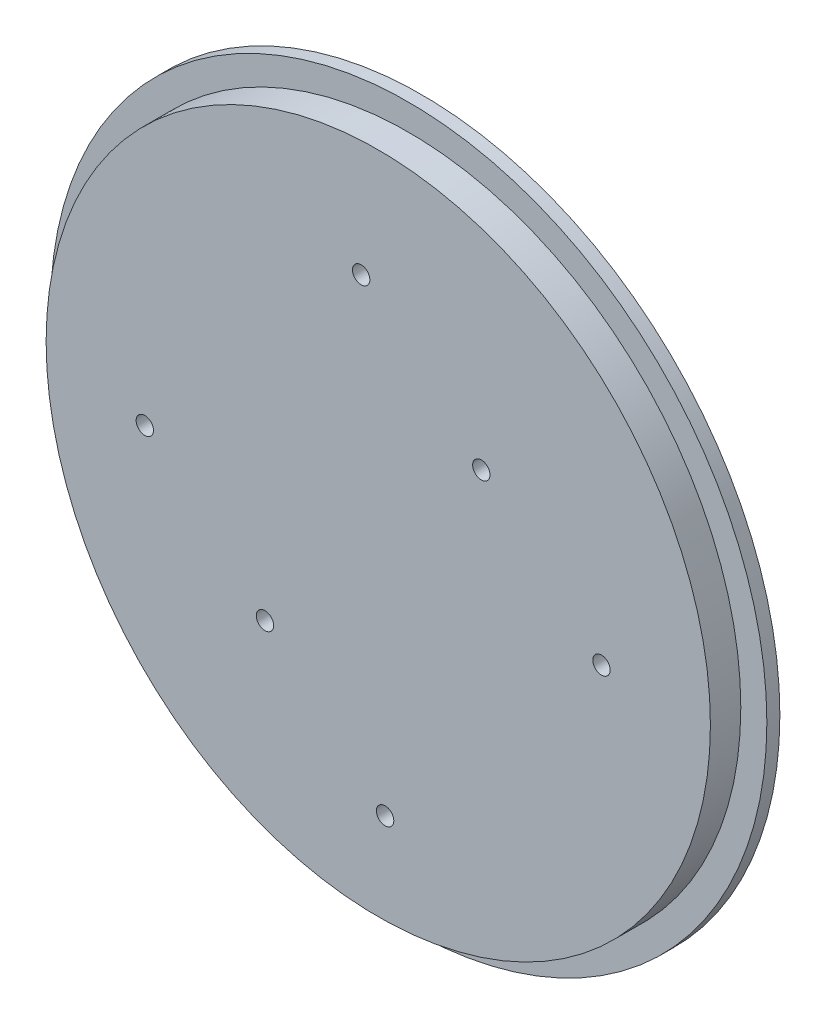
from build123d import *

# Parameters (mm, degrees)
ESBO_O1_R                = 82.5
ESBO_O1_R_2              = 14
RESSALTO_EXTRUS_O1_DEPTH = 3
ESBO_O2_R                = 5.925
RESSALTO_EXTRUS_O2_DEPTH = 8
ESBO_O3_R                = 14
RESSALTO_EXTRUS_O3_DEPTH = 3
ESBO_O4_R                = 10
RESSALTO_EXTRUS_O4_DEPTH = 11
ESBO_O5_R                = 3.05
CORTE_EXTRUS_O1_DEPTH    = 1
ESBO_O6_R                = 76.5
RESSALTO_EXTRUS_O5_DEPTH = 7
ESBO_O13_R               = 2
CORTE_EXTRUS_O2_DEPTH    = 11
ESBO_O14_R               = 7.5
CORTE_EXTRUS_O3_DEPTH    = 5


with BuildPart() as part:
    # Esboço1 → Ressalto-extrusão1 (new body)
    with BuildSketch(Plane.XY):
        Circle(ESBO_O1_R)
        Circle(ESBO_O1_R_2, mode=Mode.SUBTRACT)
    extrude(amount=RESSALTO_EXTRUS_O1_DEPTH)

    # Esboço2 → Ressalto-extrusão2 (add)
    with BuildSketch(Plane(origin=(0, 0, 0), x_dir=(-1, 0, 0), z_dir=(0, 0, -1))):
        with Locations((-55.155254038, 14.383947721)):
            Circle(ESBO_O2_R)
        with Locations((40.034491152, 40.573877288)):
            Circle(ESBO_O2_R)
        with Locations((15.120762886, -54.957825009)):
            Circle(ESBO_O2_R)
    extrude(amount=RESSALTO_EXTRUS_O2_DEPTH)

    # Esboço3 → Ressalto-extrusão3 (add)
    with BuildSketch(Plane.XY.offset(3)):
        Circle(ESBO_O3_R)
    extrude(amount=-RESSALTO_EXTRUS_O3_DEPTH)

    # Esboço4 → Ressalto-extrusão4 (add)
    with BuildSketch(Plane.XY.offset(3)):
        Circle(ESBO_O4_R)
    extrude(amount=-RESSALTO_EXTRUS_O4_DEPTH)

    # Esboço5 → Corte-extrusão1 (cut)
    with BuildSketch(Plane(origin=(0, 0, -8), x_dir=(-1, 0, 0), z_dir=(0, 0, -1))):
        Circle(ESBO_O5_R)
    extrude(amount=-CORTE_EXTRUS_O1_DEPTH, mode=Mode.SUBTRACT)

    # Esboço6 → Ressalto-extrusão5 (add)
    with BuildSketch(Plane.XY.offset(3)):
        Circle(ESBO_O6_R)
    extrude(amount=RESSALTO_EXTRUS_O5_DEPTH)

    # Esboço13 → Corte-extrusão2 (cut, through all)
    with BuildSketch(Plane(origin=(0, 0, 0), x_dir=(-1, 0, 0), z_dir=(0, 0, -1))):
        with Locations((-1.573494017, -55.549458165)):
            Circle(ESBO_O13_R)
        with Locations((26.098018566, -30.463408429)):
            Circle(ESBO_O13_R)
        with Locations((53.76953115, -5.377358693)):
            Circle(ESBO_O13_R)
        with Locations((-51.407244113, -0.579653936)):
            Circle(ESBO_O13_R)
        with Locations((-23.73573153, 24.5063958)):
            Circle(ESBO_O13_R)
        with Locations((3.935781053, 49.592445536)):
            Circle(ESBO_O13_R)
    extrude(amount=-CORTE_EXTRUS_O2_DEPTH, mode=Mode.SUBTRACT)

    # Esboço14 → Corte-extrusão3 (cut)
    with BuildSketch(Plane(origin=(0, 0, 0), x_dir=(-1, 0, 0), z_dir=(0, 0, -1))):
        with Locations((53.76953115, -5.377358693)):
            Circle(ESBO_O14_R)
        with Locations((26.098018566, -30.463408429)):
            Circle(ESBO_O14_R)
        with Locations((-1.573494017, -55.549458165)):
            Circle(ESBO_O14_R)
        with Locations((3.935781053, 49.592445536)):
            Circle(ESBO_O14_R)
        with Locations((-23.73573153, 24.5063958)):
            Circle(ESBO_O14_R)
        with Locations((-51.407244113, -0.579653936)):
            Circle(ESBO_O14_R)
    extrude(amount=-CORTE_EXTRUS_O3_DEPTH, mode=Mode.SUBTRACT)


solid = part.part
